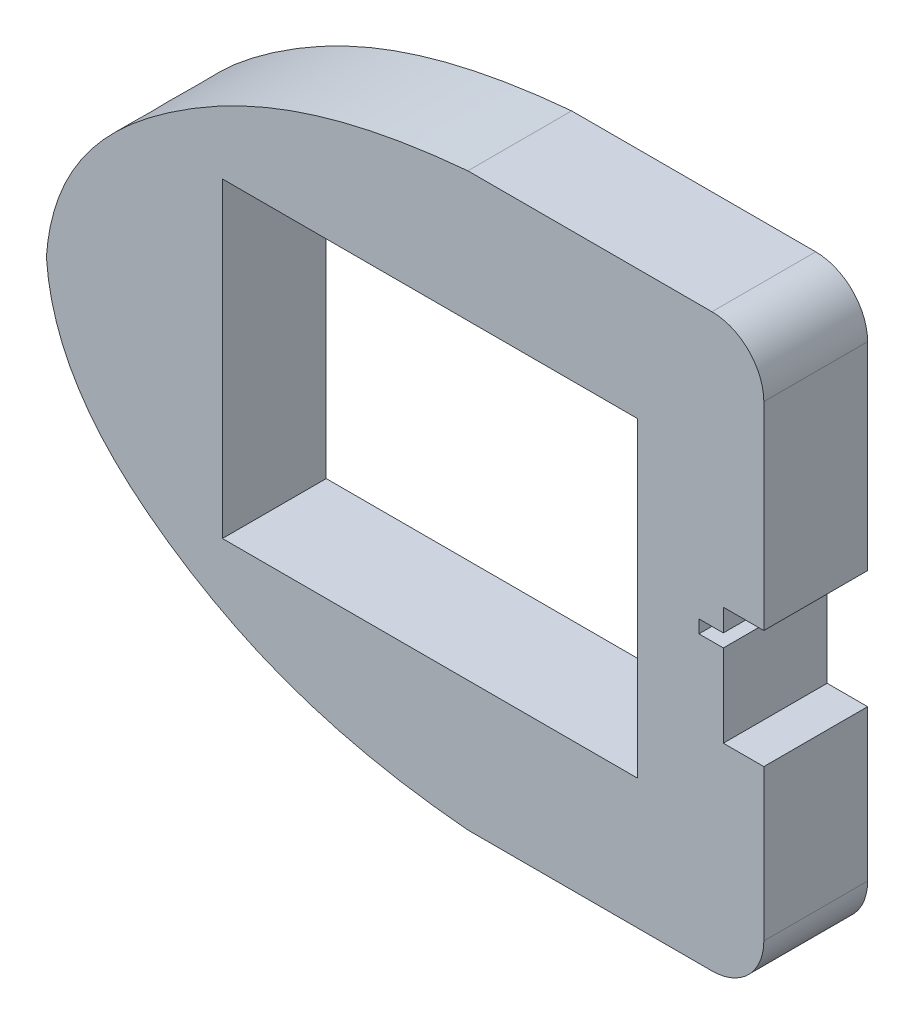
from build123d import *

# Parameters (mm, degrees)
BOSS_EXTRUDE1_DEPTH = 20
SKETCH2_W           = 80
SKETCH2_H           = 60
CUT_EXTRUDE1_DEPTH  = 20
CUT_EXTRUDE2_DEPTH  = 20
SKETCH5_R           = 1
CUT_EXTRUDE4_DEPTH  = 1


with BuildPart() as part:
    # Sketch1 → Boss-Extrude1 (new body)
    with BuildSketch(Plane.XY):
        with BuildLine():
            Line((0, 55), (47.027150271, 55))
            ThreePointArc((47.027150271, 55), (54.098218083, 52.071067812), (57.027150271, 45))
            Line((57.027150271, 45), (57.027150271, -45))
            ThreePointArc((57.027150271, -45), (54.098218083, -52.071067812), (47.027150271, -55))
            Line((47.027150271, -55), (0.441720212, -55))
            ThreePointArc((0.441720212, -55), (-0.005784399, -54.989981963), (-0.452392388, -54.959947924))
            add(Edge.make_bspline(
                [(-81.211824921, 0), (-80.030487626, -16.829502098), (-64.338425338, -33.147030622), (-38.651767748, -47.067005008), (-19.235585963, -52.655551102), (-6.275521273, -54.437200923), (-0.452392388, -54.959947924)],
                knots=[0, 0, 0, 0, 0.422832961, 0.624311743, 0.828189209, 0.995662594, 0.995662594, 0.995662594, 0.995662594], degree=3))
            add(Edge.make_bspline(
                [(-81.211824921, 0), (-80.03021452, 16.829535827), (-64.338739167, 33.146991864), (-33.323213758, 49.95438824), (-13.059438762, 53.859901845), (0, 55)],
                knots=[0, 0, 0, 0, 0.422843906, 0.624327904, 1, 1, 1, 1], degree=3))
        make_face()
    extrude(amount=BOSS_EXTRUDE1_DEPTH)

    # Sketch2 → Cut-Extrude1 (cut)
    with BuildSketch(Plane.XY.offset(20)):
        with Locations((-7.289359696, 0)):
            Rectangle(SKETCH2_W, SKETCH2_H)
    extrude(amount=-CUT_EXTRUDE1_DEPTH, mode=Mode.SUBTRACT)

    # Sketch3 → Cut-Extrude2 (cut)
    with BuildSketch(Plane.XY.offset(20)):
        Polygon((57.027150271, 6.8), (49.227150271, 6.8), (49.227150271, 2.5), (44.527150271, 2.5), (44.527150271, 0), (49.227150271, 0), (49.227150271, -15.9), (57.027150271, -15.9), align=None)
    extrude(amount=-CUT_EXTRUDE2_DEPTH, mode=Mode.SUBTRACT)

    # Sketch5 → Cut-Extrude4 (cut)
    with BuildSketch(Plane.XZ.offset(-2.5)):
        with Locations((46.927150271, 10)):
            Circle(SKETCH5_R)
    extrude(amount=-CUT_EXTRUDE4_DEPTH, mode=Mode.SUBTRACT)


solid = part.part
